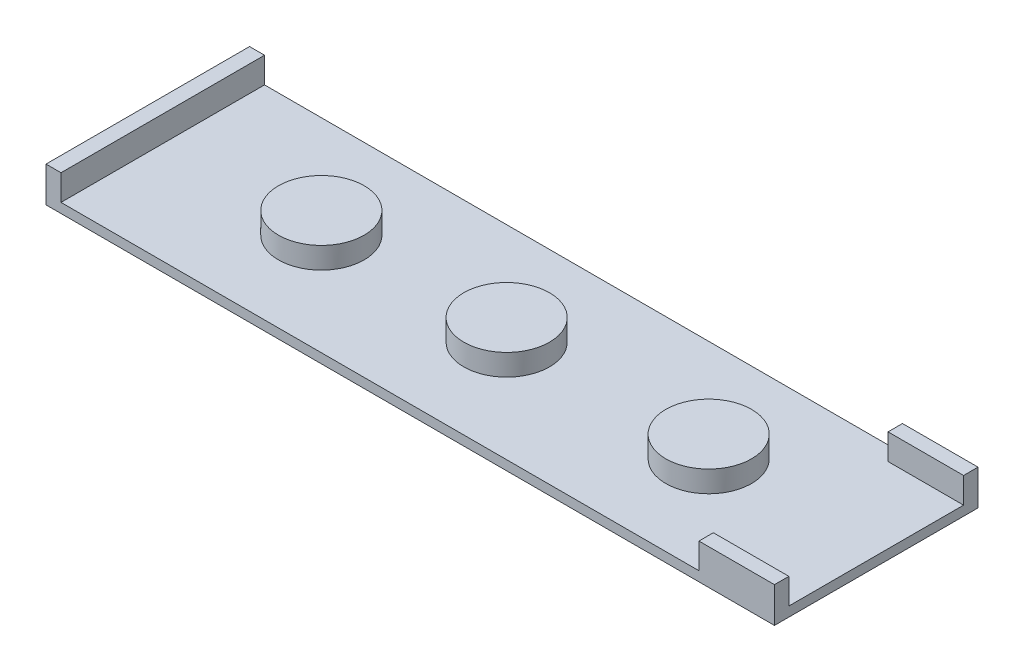
from build123d import *

# Parameters (mm, degrees)
SKETCH1_W           = 34
SKETCH1_H           = 9.5
BOSS_EXTRUDE1_DEPTH = 0.45
SKETCH2_W           = 0.7
SKETCH2_H           = 9.5
BOSS_EXTRUDE2_DEPTH = 1.2
SKETCH3_R           = 2
BOSS_EXTRUDE3_DEPTH = 1
SKETCH4_W           = 3.524824873
SKETCH4_H           = 0.673444534
SKETCH4_H_2         = 0.672160641
BOSS_EXTRUDE4_DEPTH = 1.2


with BuildPart() as part:
    # Sketch1 → Boss-Extrude1 (new body)
    with BuildSketch(Plane(origin=(0, 0, 0), x_dir=(1, 0, 0), z_dir=(0, 1, 0))):
        with Locations((5.143034826, -1.016169154)):
            Rectangle(SKETCH1_W, SKETCH1_H)
    extrude(amount=BOSS_EXTRUDE1_DEPTH)

    # Sketch2 → Boss-Extrude2 (add)
    with BuildSketch(Plane(origin=(0, 0.45, 0), x_dir=(1, 0, 0), z_dir=(0, 1, 0))):
        with Locations((-11.506965174, -1.016169154)):
            Rectangle(SKETCH2_W, SKETCH2_H)
    extrude(amount=BOSS_EXTRUDE2_DEPTH)

    # Sketch3 → Boss-Extrude3 (add)
    with BuildSketch(Plane(origin=(0, 0.45, 0), x_dir=(1, 0, 0), z_dir=(0, 1, 0))):
        with Locations((-3.756965174, -1.016169154)):
            Circle(SKETCH3_R)
        with Locations((4.893034826, -1.016169154)):
            Circle(SKETCH3_R)
        with Locations((14.323034826, -1.016169154)):
            Circle(SKETCH3_R)
    extrude(amount=BOSS_EXTRUDE3_DEPTH)

    # Sketch4 → Boss-Extrude4 (add)
    with BuildSketch(Plane(origin=(0, 0.45, 0), x_dir=(1, 0, 0), z_dir=(0, 1, 0))):
        with Locations((20.38062239, 3.397108579)):
            Rectangle(SKETCH4_W, SKETCH4_H)
        with Locations((20.38062239, -5.430088834)):
            Rectangle(SKETCH4_W, SKETCH4_H_2)
    extrude(amount=BOSS_EXTRUDE4_DEPTH)


solid = part.part
